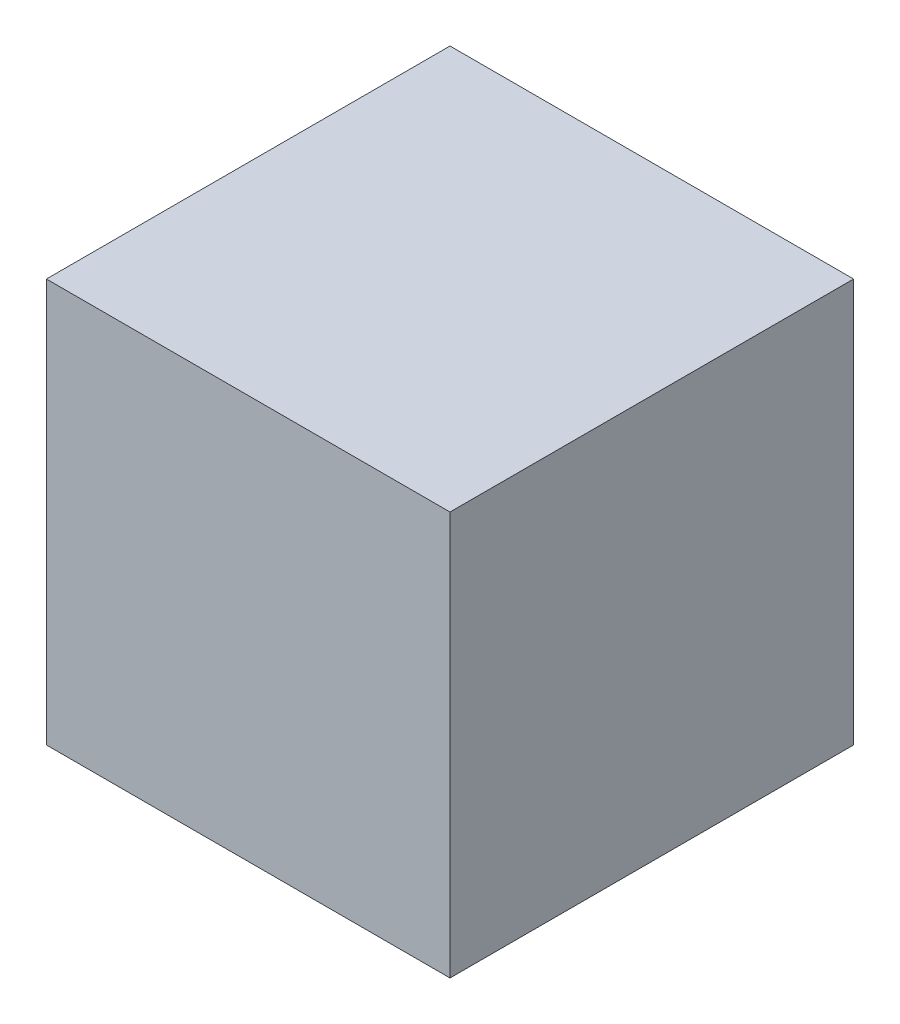
from build123d import *

# Parameters (mm, degrees)
SKETCH1_W           = 50.8
SKETCH1_H           = 50.8
BOSS_EXTRUDE1_DEPTH = 50.8


with BuildPart() as part:
    # Sketch1 → Boss-Extrude1 (new body)
    with BuildSketch(Plane(origin=(0, 0, 0), x_dir=(1, 0, 0), z_dir=(0, 1, 0))):
        Rectangle(SKETCH1_W, SKETCH1_H)
    extrude(amount=BOSS_EXTRUDE1_DEPTH)


solid = part.part
